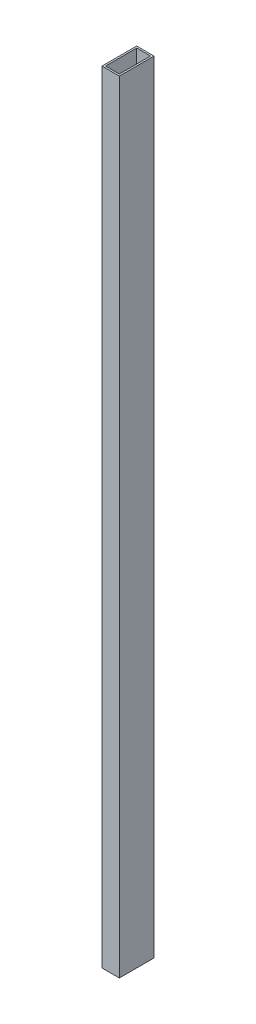
from build123d import *

# Parameters (mm, degrees)
SKETCH1_W           = 10
SKETCH1_H           = 20
SKETCH1_W_2         = 8
SKETCH1_H_2         = 18
BOSS_EXTRUDE1_DEPTH = 450


with BuildPart() as part:
    # Sketch1 → Boss-Extrude1 (new body)
    with BuildSketch(Plane(origin=(0, 0, 0), x_dir=(1, 0, 0), z_dir=(0, 1, 0))):
        Rectangle(SKETCH1_W, SKETCH1_H)
        Rectangle(SKETCH1_W_2, SKETCH1_H_2, mode=Mode.SUBTRACT)
    extrude(amount=BOSS_EXTRUDE1_DEPTH)


solid = part.part
